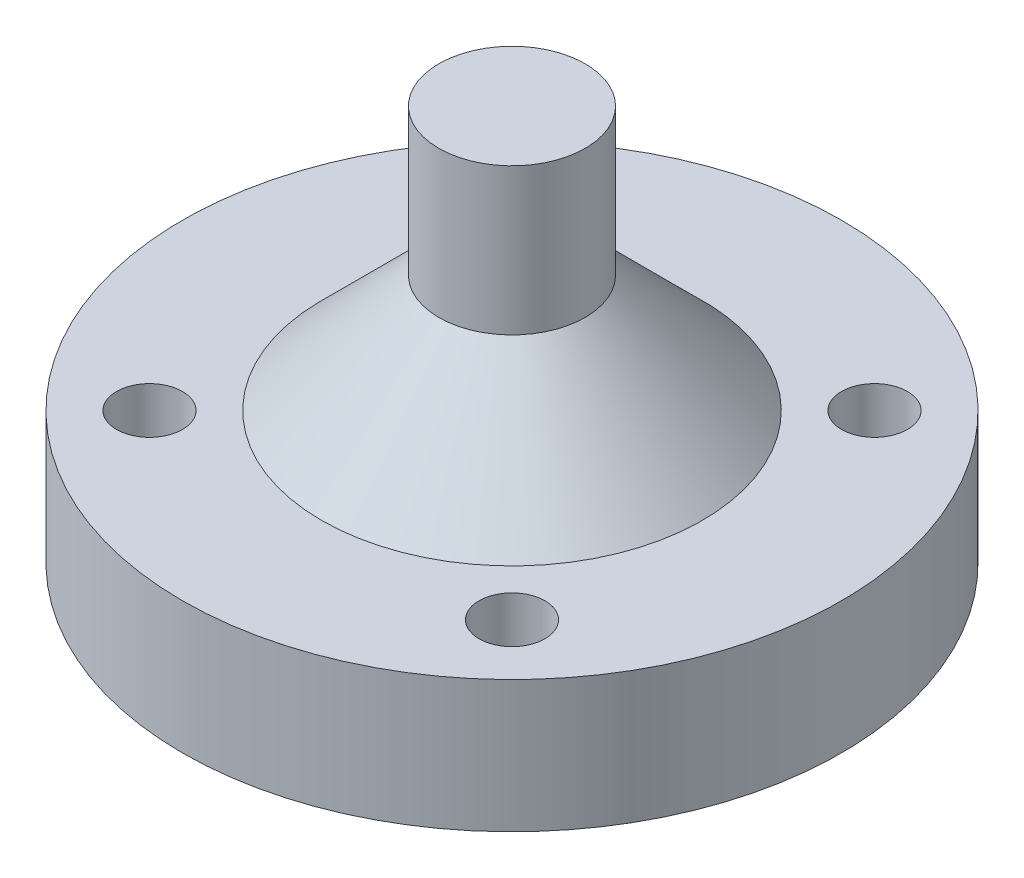
from build123d import *

# Parameters (mm, degrees)
SKETCH1_R           = 22.5
BOSS_EXTRUDE1_DEPTH = 9
SKETCH2_R           = 2.25
CUT_EXTRUDE1_DEPTH  = 10
CIRPATTERN1_COUNT   = 4
SKETCH3_R           = 5
BOSS_EXTRUDE2_DEPTH = 18
CHAMFER1_SIZE       = 8
SKETCH6_R           = 10.75
CUT_EXTRUDE4_DEPTH  = 6


with BuildPart() as part:
    # Sketch1 → Boss-Extrude1 (new body)
    with BuildSketch(Plane(origin=(0, 0, 0), x_dir=(1, 0, 0), z_dir=(0, 1, 0))):
        Circle(SKETCH1_R)
    extrude(amount=BOSS_EXTRUDE1_DEPTH)

    # Sketch2 → Cut-Extrude1 (cut, through all)
    with BuildSketch(Plane(origin=(0, 9, 0), x_dir=(1, 0, 0), z_dir=(0, 1, 0))):
        with Locations((12.374368671, 12.374368671)):
            Circle(SKETCH2_R)
    cut_extrude1 = extrude(amount=-CUT_EXTRUDE1_DEPTH, mode=Mode.SUBTRACT)

    # CirPattern1: Cut-Extrude1 ×4 about axis
    cirpattern1_axis = Axis((0, 0, 0), (0, 1, 0))
    for i in range(1, CIRPATTERN1_COUNT):
        add(cut_extrude1.rotate(cirpattern1_axis, i * 360 / CIRPATTERN1_COUNT), mode=Mode.SUBTRACT)

    # Sketch3 → Boss-Extrude2 (add)
    with BuildSketch(Plane(origin=(0, 9, 0), x_dir=(1, 0, 0), z_dir=(0, 1, 0))):
        Circle(SKETCH3_R)
    extrude(amount=BOSS_EXTRUDE2_DEPTH)

    # Chamfer1
    chamfer1_edges = [part.edges().sort_by_distance(p)[0] for p in [
        (-5, 9, 0),
    ]]
    chamfer(chamfer1_edges, length=CHAMFER1_SIZE)

    # Sketch6 → Cut-Extrude4 (cut)
    with BuildSketch(Plane.XZ):
        Circle(SKETCH6_R)
    extrude(amount=-CUT_EXTRUDE4_DEPTH, mode=Mode.SUBTRACT)


solid = part.part
